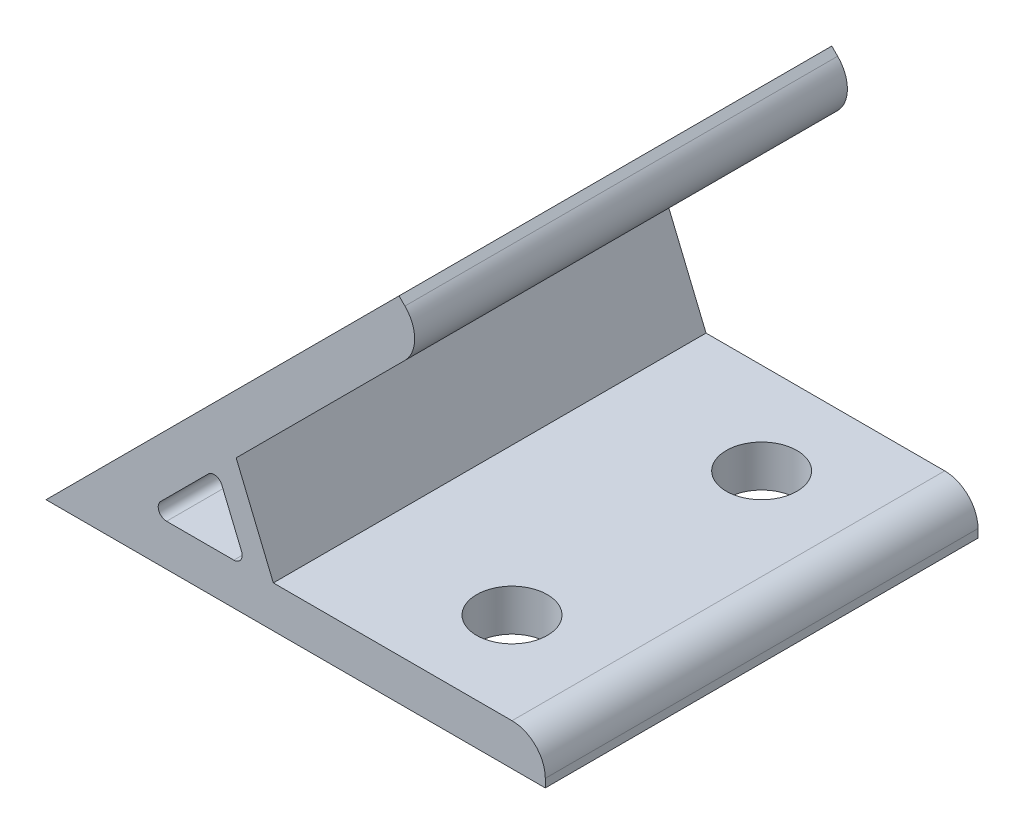
from build123d import *

# Parameters (mm, degrees)
EXTRUDE_1_DEPTH     = 26
SKETCH_2_R          = 4.25
CUT_EXTRUDE_1_DEPTH = 5
SKETCH_3_R          = 4.25
CUT_EXTRUDE_2_DEPTH = 5
FILLET_1_R          = 4
FILLET_2_R          = 1


with BuildPart() as part:
    # Эскиз1 → Бобышка-Вытянуть1 (new body, symmetric)
    with BuildSketch(Plane.XY):
        Polygon((0, 0), (42.426406871, 42.426406871), (45.961940777, 38.890872965), (22.85244978, 15.781381968), (27.318244413, 5), (60, 5), (60, 0), align=None)
        Polygon((20.556349186, 13.485281374), (24.071067812, 5), (12.071067812, 5), align=None, mode=Mode.SUBTRACT)
    extrude(amount=EXTRUDE_1_DEPTH, both=True)

    # Эскиз2 → Вырез-Вытянуть1 (cut)
    with BuildSketch(Plane(origin=(0, 0, 0), x_dir=(0, 0, 1), z_dir=(-0.707106781, 0.707106781, 0))):
        with Locations(Location((-15, 45, 0), (0, 0, 270))):  # turned: the seam where the file's is
            Circle(SKETCH_2_R)
        with Locations(Location((15, 45, 0), (0, 0, 270))):  # turned: the seam where the file's is
            Circle(SKETCH_2_R)
    extrude(amount=-CUT_EXTRUDE_1_DEPTH, mode=Mode.SUBTRACT)

    # Эскиз3 → Вырез-Вытянуть2 (cut)
    with BuildSketch(Plane.XZ):
        with Locations(Location((45, 15, 0), (0, 0, 270))):  # turned: the seam where the file's is
            Circle(SKETCH_3_R)
        with Locations(Location((45, -15, 0), (0, 0, 270))):  # turned: the seam where the file's is
            Circle(SKETCH_3_R)
    extrude(amount=-CUT_EXTRUDE_2_DEPTH, mode=Mode.SUBTRACT)

    # Скругление1
    fillet_1_edges = [part.edges().sort_by_distance(p)[0] for p in [
        (45.961940777, 38.890872965, 0),
        (60, 5, 0),
    ]]
    fillet(fillet_1_edges, radius=FILLET_1_R)

    # Скругление2
    fillet_2_edges = [part.edges().sort_by_distance(p)[0] for p in [
        (20.556349186, 13.485281374, 0),
        (12.071067812, 5, 0),
        (24.071067812, 5, 0),
    ]]
    fillet(fillet_2_edges, radius=FILLET_2_R)


solid = part.part
